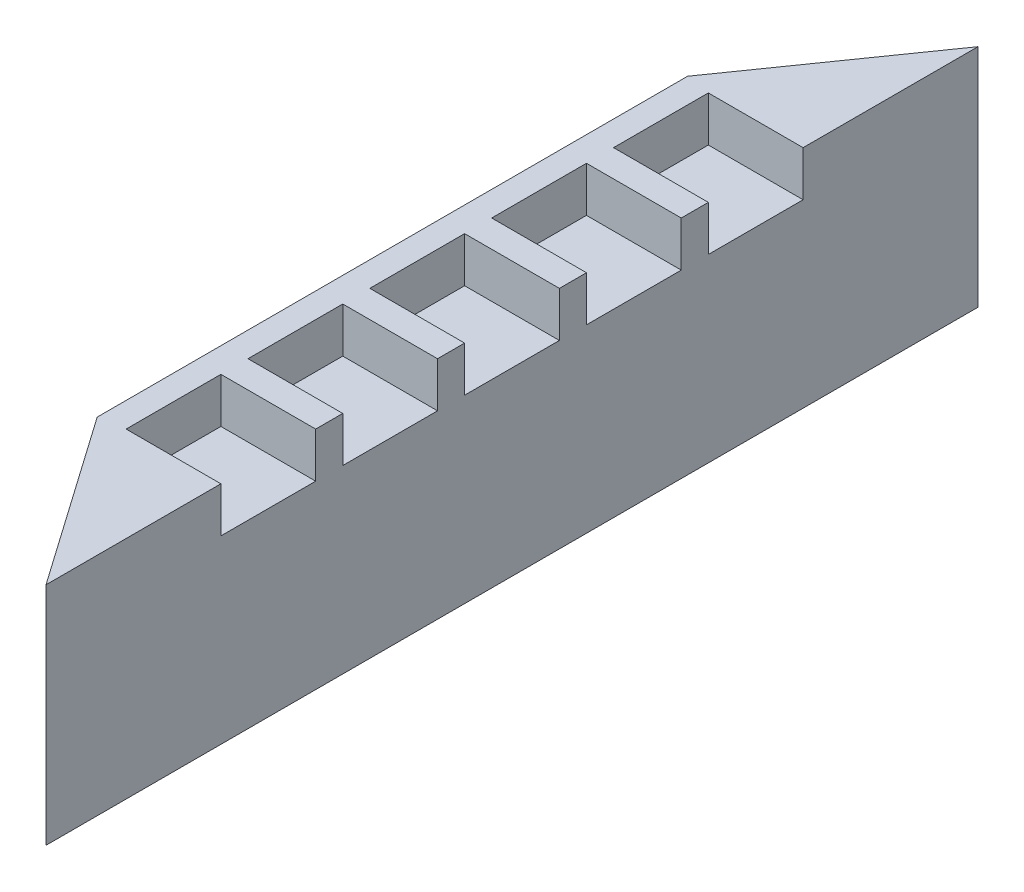
from build123d import *

# Parameters (mm, degrees)
EXTRUDE_1_DEPTH             = 500
SKETCH_2_W                  = 210
SKETCH_2_H                  = 100
CUT_EXTRUDE_1_DEPTH         = 105
PATTERN_LINEAR_1_COUNT      = 3
PATTERN_LINEAR_1_PITCH      = 270
PATTERN_LINEAR_1_COUNT_DIR2 = 3
PATTERN_LINEAR_1_PITCH_DIR2 = 270


with BuildPart() as part:
    # 草图1 → 凸台-拉伸1 (new body)
    with BuildSketch(Plane(origin=(0, 0, 0), x_dir=(1, 0, 0), z_dir=(0, 1, 0))):
        Polygon((0, 1032.5), (0, -1032.5), (-265, -654.040778213), (-265, 654.040778213), align=None)
    extrude(amount=EXTRUDE_1_DEPTH)

    # 草图2 → 切除-拉伸1 (cut, symmetric)
    with BuildSketch(Plane.XY):
        with Locations((-105, 450)):
            Rectangle(SKETCH_2_W, SKETCH_2_H)
    cut_extrude_1 = extrude(amount=CUT_EXTRUDE_1_DEPTH, both=True, mode=Mode.SUBTRACT)

    # 阵列(线性)1: Cut-Extrude 1 3 × 3
    with Locations(*[Vector(0, 0, 1) * (i * PATTERN_LINEAR_1_PITCH) + Vector(0, 0, -1) * (j * PATTERN_LINEAR_1_PITCH_DIR2) for i in range(PATTERN_LINEAR_1_COUNT) for j in range(PATTERN_LINEAR_1_COUNT_DIR2) if (i, j) != (0, 0)]):
        add(cut_extrude_1, mode=Mode.SUBTRACT)


solid = part.part
